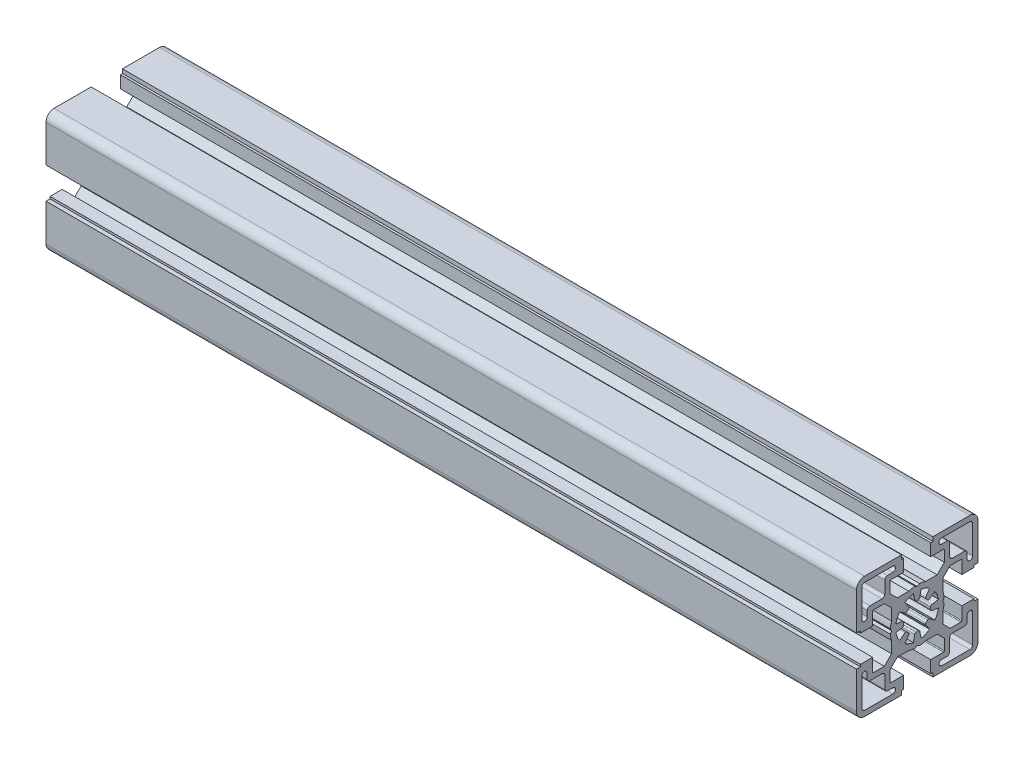
from build123d import *

# Parameters (mm, degrees)
EXTRUDE_1_DEPTH     = 300
CUT_EXTRUDE_1_DEPTH = 301


with BuildPart() as part:
    # Эскиз2 → Бобышка-Вытянуть1 (new body)
    with BuildSketch(Plane(origin=(0, 0, 0), x_dir=(0, 0, -1), z_dir=(1, 0, 0))):
        with BuildLine():
            Line((16.5, 5), (21, 5))
            Line((21, 5), (21, 5.799999))
            Line((21, 5.799999), (22.5, 5.799999))
            Line((22.5, 5.799999), (22.5, 19.5))
            ThreePointArc((22.5, 19.5), (21.621320344, 21.621320344), (19.5, 22.5))
            Line((19.5, 22.5), (5.799999, 22.5))
            Line((5.799999, 22.5), (5.799999, 21))
            Line((5.799999, 21), (5, 21))
            Line((5, 21), (5, 16.5))
            Line((5, 16.5), (9.75, 16.5))
            ThreePointArc((9.75, 16.5), (9.962132034, 16.412132034), (10.05, 16.2))
            Line((10.05, 16.2), (10.05, 12.171320344))
            Line((10.05, 12.171320344), (7.378679656, 9.5))
            Line((7.378679656, 9.5), (3.122498999, 9.5))
            ThreePointArc((3.122498999, 9.5), (2.007620973, 9.796400259), (0.866025404, 9.962429423))
            Line((0.866025404, 9.962429423), (0, 9.462429423))
            Line((0, 9.462429423), (-0.866025404, 9.962429423))
            ThreePointArc((-0.866025404, 9.962429423), (-2.007620973, 9.796400259), (-3.122498999, 9.5))
            Line((-3.122498999, 9.5), (-7.378679656, 9.5))
            Line((-7.378679656, 9.5), (-10.049999, 12.171319344))
            Line((-10.049999, 12.171319344), (-10.049999, 16.2))
            ThreePointArc((-10.049999, 16.2), (-9.962131034, 16.412132034), (-9.749999, 16.5))
            Line((-9.749999, 16.5), (-5, 16.5))
            Line((-5, 16.5), (-5, 21))
            Line((-5, 21), (-5.799999, 21))
            Line((-5.799999, 21), (-5.799999, 22.5))
            Line((-5.799999, 22.5), (-19.5, 22.5))
            ThreePointArc((-19.5, 22.5), (-21.621320344, 21.621320344), (-22.5, 19.5))
            Line((-22.5, 19.5), (-22.5, 5.799999))
            Line((-22.5, 5.799999), (-21, 5.799999))
            Line((-21, 5.799999), (-21, 5))
            Line((-21, 5), (-16.5, 5))
            Line((-16.5, 5), (-16.5, 9.749999))
            ThreePointArc((-16.5, 9.749999), (-16.412132034, 9.962131034), (-16.2, 10.049999))
            Line((-16.2, 10.049999), (-12.171319344, 10.049999))
            Line((-12.171319344, 10.049999), (-9.5, 7.378679656))
            Line((-9.5, 7.378679656), (-9.5, 3.122498999))
            ThreePointArc((-9.5, 3.122498999), (-9.796400259, 2.007620973), (-9.962429423, 0.866025404))
            Line((-9.962429423, 0.866025404), (-9.462429423, 0))
            Line((-9.462429423, 0), (-9.962429423, -0.866025404))
            ThreePointArc((-9.962429423, -0.866025404), (-9.796400259, -2.007620973), (-9.5, -3.122498999))
            Line((-9.5, -3.122498999), (-9.5, -7.378679656))
            Line((-9.5, -7.378679656), (-12.171320344, -10.05))
            Line((-12.171320344, -10.05), (-16.2, -10.05))
            ThreePointArc((-16.2, -10.05), (-16.412132034, -9.962132034), (-16.5, -9.75))
            Line((-16.5, -9.75), (-16.5, -5))
            Line((-16.5, -5), (-21, -5))
            Line((-21, -5), (-21, -5.799999))
            Line((-21, -5.799999), (-22.5, -5.799999))
            Line((-22.5, -5.799999), (-22.5, -19.5))
            ThreePointArc((-22.5, -19.5), (-21.621320344, -21.621320344), (-19.5, -22.5))
            Line((-19.5, -22.5), (-5.799999, -22.5))
            Line((-5.799999, -22.5), (-5.799999, -21))
            Line((-5.799999, -21), (-5, -21))
            Line((-5, -21), (-5, -16.5))
            Line((-5, -16.5), (-9.749999, -16.5))
            ThreePointArc((-9.749999, -16.5), (-9.962131034, -16.412132034), (-10.049999, -16.2))
            Line((-10.049999, -16.2), (-10.049999, -12.171319344))
            Line((-10.049999, -12.171319344), (-7.378679656, -9.5))
            Line((-7.378679656, -9.5), (-3.122498999, -9.5))
            ThreePointArc((-3.122498999, -9.5), (-2.007620973, -9.796400259), (-0.866025404, -9.962429423))
            Line((-0.866025404, -9.962429423), (0, -9.462429423))
            Line((0, -9.462429423), (0.866025404, -9.962429423))
            ThreePointArc((0.866025404, -9.962429423), (2.007620973, -9.796400259), (3.122498999, -9.5))
            Line((3.122498999, -9.5), (7.378679656, -9.5))
            Line((7.378679656, -9.5), (10.05, -12.171320344))
            Line((10.05, -12.171320344), (10.05, -16.2))
            ThreePointArc((10.05, -16.2), (9.962132034, -16.412132034), (9.75, -16.5))
            Line((9.75, -16.5), (5, -16.5))
            Line((5, -16.5), (5, -21))
            Line((5, -21), (5.799999, -21))
            Line((5.799999, -21), (5.799999, -22.5))
            Line((5.799999, -22.5), (19.5, -22.5))
            ThreePointArc((19.5, -22.5), (21.621320344, -21.621320344), (22.5, -19.5))
            Line((22.5, -19.5), (22.5, -5.799999))
            Line((22.5, -5.799999), (21, -5.799999))
            Line((21, -5.799999), (21, -5))
            Line((21, -5), (16.5, -5))
            Line((16.5, -5), (16.5, -9.75))
            ThreePointArc((16.5, -9.75), (16.412132034, -9.962132034), (16.2, -10.05))
            Line((16.2, -10.05), (12.171320344, -10.05))
            Line((12.171320344, -10.05), (9.5, -7.378679656))
            Line((9.5, -7.378679656), (9.5, -3.122498999))
            ThreePointArc((9.5, -3.122498999), (9.796400259, -2.007620973), (9.962429423, -0.866025404))
            Line((9.962429423, -0.866025404), (9.462429423, 0))
            Line((9.462429423, 0), (9.962429423, 0.866025404))
            ThreePointArc((9.962429423, 0.866025404), (9.796400259, 2.007620973), (9.5, 3.122498999))
            Line((9.5, 3.122498999), (9.5, 7.378679656))
            Line((9.5, 7.378679656), (12.171319344, 10.049999))
            Line((12.171319344, 10.049999), (16.2, 10.049999))
            ThreePointArc((16.2, 10.049999), (16.412132034, 9.962131034), (16.5, 9.749999))
            Line((16.5, 9.749999), (16.5, 5))
        make_face()
    extrude(amount=EXTRUDE_1_DEPTH)

    # Эскиз3 → Вырез-Вытянуть1 (cut, through all)
    with BuildSketch(Plane.ZY):
        with BuildLine():
            Line((-0.951109584, 5.394014463), (-1.38918508, 7.878462452))
            ThreePointArc((-1.38918508, 7.878462452), (-3.061467429, 7.391036664), (-4.588611737, 6.553216624))
            Line((-4.588611737, 6.553216624), (-3.14160736, 4.486680308))
            ThreePointArc((-3.14160736, 4.486680308), (-3.055338858, 4.135563126), (-3.228348507, 3.81808369))
            ThreePointArc((-3.228348507, 3.81808369), (-3.535533704, 3.535533704), (-3.81808369, 3.228348507))
            ThreePointArc((-3.81808369, 3.228348507), (-4.135563126, 3.055338858), (-4.486680308, 3.14160736))
            Line((-4.486680308, 3.14160736), (-6.553216624, 4.588611737))
            ThreePointArc((-6.553216624, 4.588611737), (-7.391036664, 3.061467429), (-7.878462452, 1.38918508))
            Line((-7.878462452, 1.38918508), (-5.394014463, 0.951109584))
            ThreePointArc((-5.394014463, 0.951109584), (-5.084736142, 0.763833295), (-4.982580573, 0.417005199))
            ThreePointArc((-4.982580573, 0.417005199), (-5.000000251, 0), (-4.982580573, -0.417005199))
            ThreePointArc((-4.982580573, -0.417005199), (-5.084736142, -0.763833295), (-5.394014463, -0.951109584))
            Line((-5.394014463, -0.951109584), (-7.878461766, -1.389184959))
            ThreePointArc((-7.878461766, -1.389184959), (-7.391036076, -3.06146703), (-6.553216219, -4.588611102))
            Line((-6.553216219, -4.588611102), (-4.486680308, -3.14160736))
            ThreePointArc((-4.486680308, -3.14160736), (-4.135563126, -3.055338858), (-3.81808369, -3.228348507))
            ThreePointArc((-3.81808369, -3.228348507), (-3.535533733, -3.535533675), (-3.22834857, -3.818083636))
            ThreePointArc((-3.22834857, -3.818083636), (-3.055338921, -4.135563118), (-3.141607485, -4.486680327))
            Line((-3.141607485, -4.486680327), (-4.588611972, -6.55321596))
            ThreePointArc((-4.588611972, -6.55321596), (-3.061467529, -7.39103618), (-1.38918499, -7.878462052))
            Line((-1.38918499, -7.878462052), (-0.951109584, -5.394014463))
            ThreePointArc((-0.951109584, -5.394014463), (-0.763833295, -5.084736142), (-0.417005199, -4.982580573))
            ThreePointArc((-0.417005199, -4.982580573), (0, -5.000000251), (0.417005199, -4.982580573))
            ThreePointArc((0.417005199, -4.982580573), (0.763833295, -5.084736142), (0.951109584, -5.394014463))
            Line((0.951109584, -5.394014463), (1.389184959, -7.878461766))
            ThreePointArc((1.389184959, -7.878461766), (3.061467283, -7.391035971), (4.58861155, -6.553215905))
            Line((4.58861155, -6.553215905), (3.141607485, -4.486680327))
            ThreePointArc((3.141607485, -4.486680327), (3.055338921, -4.135563118), (3.22834857, -3.818083636))
            ThreePointArc((3.22834857, -3.818083636), (3.535533704, -3.535533704), (3.818083636, -3.22834857))
            ThreePointArc((3.818083636, -3.22834857), (4.135563118, -3.055338921), (4.486680327, -3.141607485))
            Line((4.486680327, -3.141607485), (6.55321596, -4.588611972))
            ThreePointArc((6.55321596, -4.588611972), (7.39103618, -3.061467529), (7.878462052, -1.38918499))
            Line((7.878462052, -1.38918499), (5.394014463, -0.951109584))
            ThreePointArc((5.394014463, -0.951109584), (5.084736142, -0.763833295), (4.982580573, -0.417005199))
            ThreePointArc((4.982580573, -0.417005199), (5.000000251, 0), (4.982580573, 0.417005199))
            ThreePointArc((4.982580573, 0.417005199), (5.084736142, 0.763833295), (5.394014463, 0.951109584))
            Line((5.394014463, 0.951109584), (7.878462049, 1.389185009))
            ThreePointArc((7.878462049, 1.389185009), (7.391036176, 3.061467538), (6.55321596, 4.588611972))
            Line((6.55321596, 4.588611972), (4.486680327, 3.141607485))
            ThreePointArc((4.486680327, 3.141607485), (4.135563118, 3.055338921), (3.818083636, 3.22834857))
            ThreePointArc((3.818083636, 3.22834857), (3.535533675, 3.535533733), (3.228348507, 3.81808369))
            ThreePointArc((3.228348507, 3.81808369), (3.055338858, 4.135563126), (3.14160736, 4.486680308))
            Line((3.14160736, 4.486680308), (4.588611737, 6.553216624))
            ThreePointArc((4.588611737, 6.553216624), (3.061467429, 7.391036664), (1.38918508, 7.878462452))
            Line((1.38918508, 7.878462452), (0.951109584, 5.394014463))
            ThreePointArc((0.951109584, 5.394014463), (0.763833295, 5.084736142), (0.417005199, 4.982580573))
            ThreePointArc((0.417005199, 4.982580573), (0, 5.000000251), (-0.417005199, 4.982580573))
            ThreePointArc((-0.417005199, 4.982580573), (-0.763833295, 5.084736142), (-0.951109584, 5.394014463))
        make_face()
        with BuildLine():
            Line((-17.5, 12), (-13, 12))
            ThreePointArc((-13, 12), (-12.292894344, 12.292894094), (-12.000002, 13.000000474))
            Line((-12.000002, 13.000000474), (-12, 17.5))
            ThreePointArc((-12, 17.5), (-11.707106781, 18.207106781), (-11, 18.5))
            Line((-11, 18.5), (-9, 18.5))
            ThreePointArc((-9, 18.5), (-8, 19.5), (-9, 20.5))
            Line((-9, 20.5), (-19.5, 20.5))
            ThreePointArc((-19.5, 20.5), (-20.207106781, 20.207106781), (-20.5, 19.5))
            Line((-20.5, 19.5), (-20.5, 9))
            ThreePointArc((-20.5, 9), (-19.5, 8), (-18.5, 9))
            Line((-18.5, 9), (-18.5, 11))
            ThreePointArc((-18.5, 11), (-18.207106781, 11.707106781), (-17.5, 12))
        make_face()
        with BuildLine():
            Line((17.5, 12), (13.000000474, 12.000002))
            ThreePointArc((13.000000474, 12.000002), (12.292894094, 12.292894344), (12, 13))
            Line((12, 13), (12, 17.5))
            ThreePointArc((12, 17.5), (11.707106781, 18.207106781), (11, 18.5))
            Line((11, 18.5), (9, 18.5))
            ThreePointArc((9, 18.5), (8, 19.5), (9, 20.5))
            Line((9, 20.5), (19.5, 20.5))
            ThreePointArc((19.5, 20.5), (20.207106781, 20.207106781), (20.5, 19.5))
            Line((20.5, 19.5), (20.5, 9))
            ThreePointArc((20.5, 9), (19.5, 8), (18.5, 9))
            Line((18.5, 9), (18.5, 11))
            ThreePointArc((18.5, 11), (18.207106781, 11.707106781), (17.5, 12))
        make_face()
        with BuildLine():
            Line((-17.5, -12), (-13.000000474, -12.000002))
            ThreePointArc((-13.000000474, -12.000002), (-12.292894094, -12.292894344), (-12, -13))
            Line((-12, -13), (-12, -17.5))
            ThreePointArc((-12, -17.5), (-11.707106781, -18.207106781), (-11, -18.5))
            Line((-11, -18.5), (-9, -18.5))
            ThreePointArc((-9, -18.5), (-8, -19.5), (-9, -20.5))
            Line((-9, -20.5), (-19.5, -20.5))
            ThreePointArc((-19.5, -20.5), (-20.207106781, -20.207106781), (-20.5, -19.5))
            Line((-20.5, -19.5), (-20.5, -9))
            ThreePointArc((-20.5, -9), (-19.5, -8), (-18.5, -9))
            Line((-18.5, -9), (-18.5, -11))
            ThreePointArc((-18.5, -11), (-18.207106781, -11.707106781), (-17.5, -12))
        make_face()
        with BuildLine():
            Line((19.5, -20.5), (9, -20.5))
            ThreePointArc((9, -20.5), (8, -19.5), (9, -18.5))
            Line((9, -18.5), (11, -18.5))
            ThreePointArc((11, -18.5), (11.707106781, -18.207106781), (12, -17.5))
            Line((12, -17.5), (12.000002, -13.000000474))
            ThreePointArc((12.000002, -13.000000474), (12.292894344, -12.292894094), (13, -12))
            Line((13, -12), (17.5, -12))
            ThreePointArc((17.5, -12), (18.207106781, -11.707106781), (18.5, -11))
            Line((18.5, -11), (18.5, -9))
            ThreePointArc((18.5, -9), (19.5, -8), (20.5, -9))
            Line((20.5, -9), (20.5, -19.5))
            ThreePointArc((20.5, -19.5), (20.207106781, -20.207106781), (19.5, -20.5))
        make_face()
    extrude(amount=-CUT_EXTRUDE_1_DEPTH, mode=Mode.SUBTRACT)


solid = part.part
